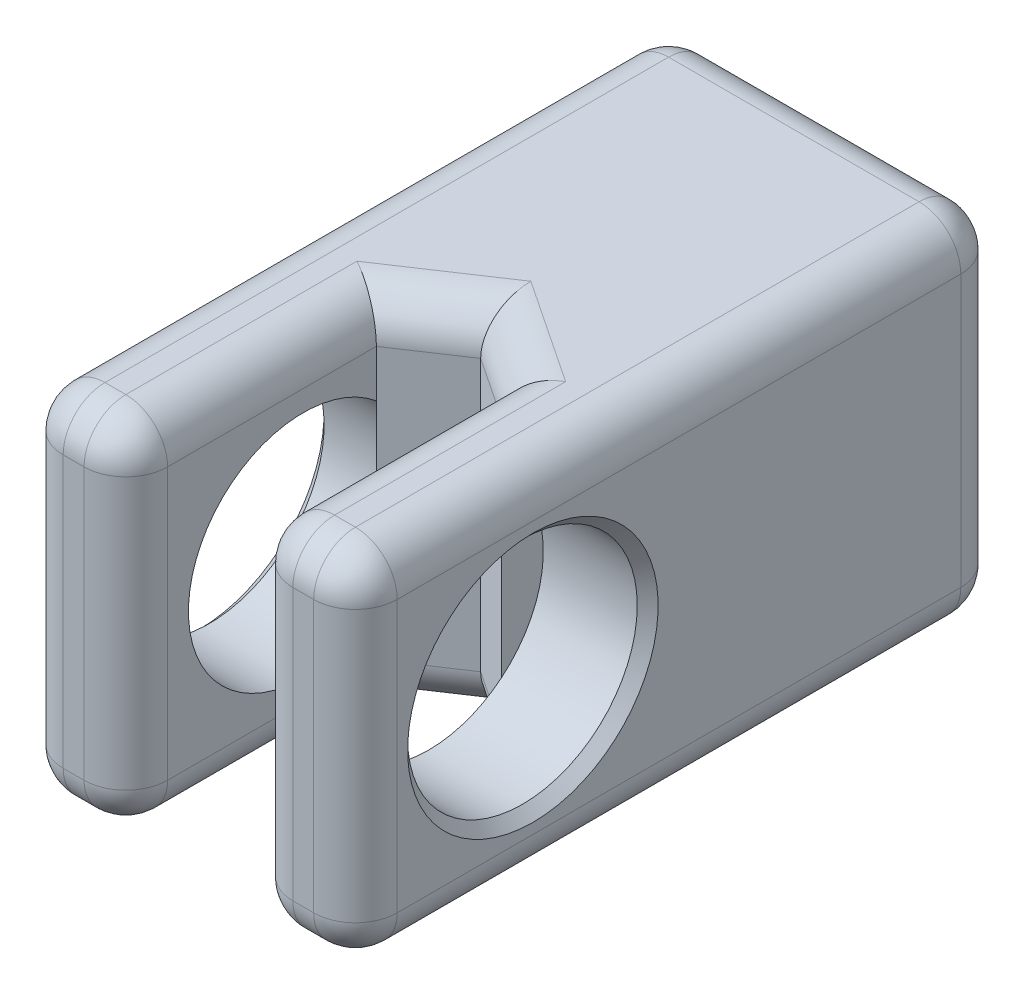
from build123d import *

# Parameters (mm, degrees)
SKETCH1_W           = 16
SKETCH1_H           = 17
SKETCH1_R           = 4
BOSS_EXTRUDE1_DEPTH = 15
SKETCH2_W           = 5
SKETCH2_H           = 17
BOSS_EXTRUDE2_DEPTH = 16
SKETCH3_R           = 5.5
CUT_EXTRUDE3_DEPTH  = 16
BOSS_EXTRUDE5_DEPTH = 17
SKETCH5_R           = 1.25
CUT_EXTRUDE4_DEPTH  = 17
FILLET1_R           = 2
CHAMFER1_SIZE       = 0.5


with BuildPart() as part:
    # Sketch1 → Boss-Extrude1 (new body)
    with BuildSketch(Plane.XY):
        Rectangle(SKETCH1_W, SKETCH1_H)
        Circle(SKETCH1_R, mode=Mode.SUBTRACT)
    extrude(amount=BOSS_EXTRUDE1_DEPTH)

    # Sketch2 → Boss-Extrude2 (add)
    with BuildSketch(Plane.XY.offset(15)):
        with Locations((-5.5, 0)):
            Rectangle(SKETCH2_W, SKETCH2_H)
        with Locations((5.5, 0)):
            Rectangle(SKETCH2_W, SKETCH2_H)
    extrude(amount=BOSS_EXTRUDE2_DEPTH)

    # Sketch3 → Cut-Extrude3 (cut)
    with BuildSketch(Plane.ZY.offset(8)):
        with Locations((22.5, 0)):
            Circle(SKETCH3_R)
    extrude(amount=-CUT_EXTRUDE3_DEPTH, mode=Mode.SUBTRACT)

    # Sketch4 → Boss-Extrude5 (add, through all)
    with BuildSketch(Plane.XZ.offset(8.5)):
        Polygon((-3, 19), (-3, 15), (0, 15), (3, 15), (3, 19), (0, 17), align=None)
    extrude(amount=-BOSS_EXTRUDE5_DEPTH)

    # Sketch5 → Cut-Extrude4 (cut, through all)
    with BuildSketch(Plane(origin=(0, 0, 15), x_dir=(-1, 0, 0), z_dir=(0, 0, -1))):
        Circle(SKETCH5_R)
    extrude(amount=-CUT_EXTRUDE4_DEPTH, mode=Mode.SUBTRACT)

    # Fillet1
    fillet1_edges = [part.edges().sort_by_distance(p)[0] for p in [
        (-3, 8.5, 25),
        (-3, -8.5, 25),
        (-5.5, 8.5, 31),
        (-8, 0, 31),
        (-5.5, -8.5, 31),
        (-3, 0, 31),
        (3, 8.5, 25),
        (3, -8.5, 25),
        (5.5, 8.5, 31),
        (3, 0, 31),
        (5.5, -8.5, 31),
        (8, 0, 31),
        (0, -8.5, 0),
        (-8, 0, 0),
        (0, 8.5, 0),
        (8, 0, 0),
        (-1.5, 8.5, 18),
        (1.5, 8.5, 18),
        (1.5, -8.5, 18),
        (-1.5, -8.5, 18),
        (8, -8.5, 15.5),
        (-8, -8.5, 15.5),
        (-8, 8.5, 15.5),
        (8, 8.5, 15.5),
    ]]
    fillet(fillet1_edges, radius=FILLET1_R)

    # Chamfer1
    chamfer1_edges = [part.edges().sort_by_distance(p)[0] for p in [
        (-4, 0, 0),
        (8, 0, 17),
        (-8, 0, 17),
    ]]
    chamfer(chamfer1_edges, length=CHAMFER1_SIZE)


solid = part.part
